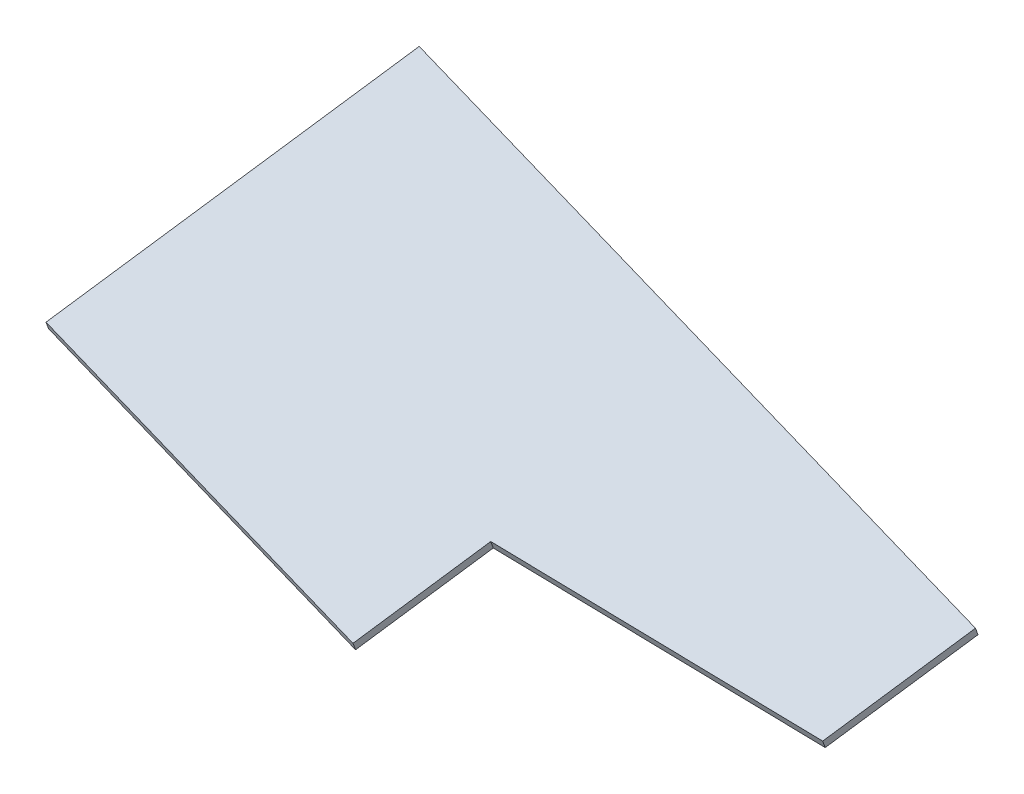
from build123d import *

# Parameters (mm, degrees)
BOSS_EXTRUDE1_DEPTH = 3


with BuildPart() as part:
    # Sketch1 → Boss-Extrude1 (new body)
    with BuildSketch(Plane(origin=(270.562015017, 2929.868417667, 1339.312972046), x_dir=(0.933919841, -0.218343191, 0.283054733), z_dir=(-0.093635076, -0.913565758, -0.395765181))):
        Polygon((-317.0861634, -434.442381086), (-183.365674706, -452.985058966), (-189.410130107, -496.574638387), (-84.476991235, -537.792492394), (-91.181057549, -586.138854741), (-199.742283926, -571.084947366), (-333.462772622, -552.542269486), align=None)
    extrude(amount=-BOSS_EXTRUDE1_DEPTH)


solid = part.part
